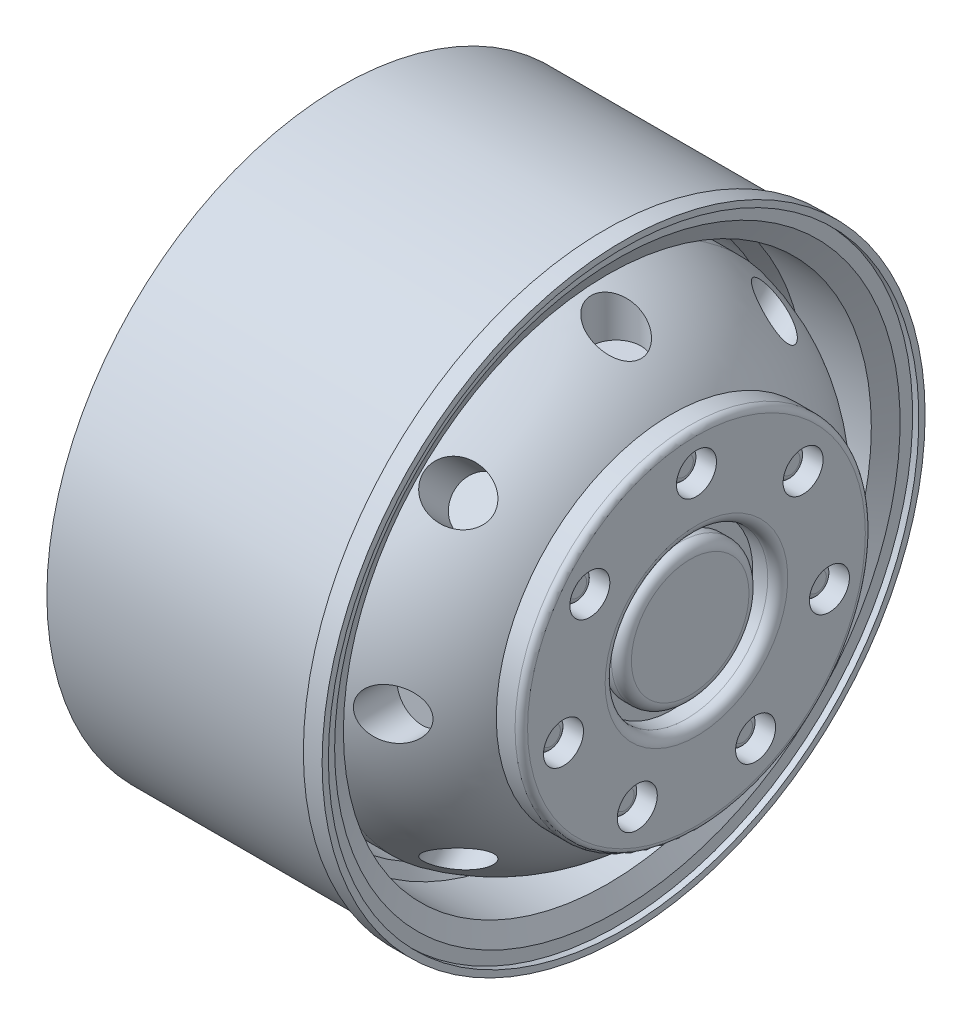
from build123d import *

# Parameters (mm, degrees)
SKETCH2_R           = 6.5
SKETCH2_R_2         = 1.6
CUT_EXTRUDE1_DEPTH  = 2
FILLET1_R           = 0.5
SKETCH3_R           = 1.25
BOSS_EXTRUDE1_DEPTH = 1
FILLET2_R           = 0.5
SKETCH4_R           = 5.5
BOSS_EXTRUDE2_DEPTH = 1.5
FILLET3_R           = 0.8
FILLET4_R           = 0.8
SKETCH6_R           = 2
CUT_EXTRUDE2_DEPTH  = 2.5
CIRPATTERN1_COUNT   = 8


with BuildPart() as part:
    # Sketch1 → Revolve1 (revolve)
    with BuildSketch(Plane.XY):
        with BuildLine():
            Line((-10, 23.5), (11.1, 23.5))
            Line((11.1, 23.5), (11.1, 24.1))
            Line((11.1, 24.1), (12.6, 24.1))
            Line((12.6, 24.1), (12.6, 23.6))
            Line((12.6, 23.6), (12.1, 23.6))
            Line((12.1, 23.6), (12.1, 22.6))
            Line((12.1, 22.6), (11.3, 21.1))
            Line((11.3, 21.1), (6, 21.1))
            Line((6, 21.1), (5.01570057, 20.3))
            Line((5.01570057, 20.3), (0, 20.1))
            Line((0, 20.1), (0, 19.6))
            Line((0, 19.6), (8, 19.6))
            ThreePointArc((8, 19.6), (12.733644996, 17.586085974), (16.421900958, 14))
            Line((16.421900958, 14), (18.421900958, 14))
            Line((18.421900958, 14), (18.421900958, 0))
            Line((18.421900958, 0), (-1.578099042, 0))
            Line((-1.578099042, 0), (-1.460697094, 16.5))
            Line((-1.460697094, 16.5), (-10, 16.5))
            Line((-10, 16.5), (-10, 21.1))
            Line((-10, 21.1), (-10, 23.5))
        make_face()
    revolve(axis=Axis((-25, 0, 0), (1, 0, 0)))

    # Sketch2 → Cut-Extrude1 (cut)
    with BuildSketch(Plane(origin=(18.421900958, 0, 0), x_dir=(0, 0, -1), z_dir=(1, 0, 0))):
        Circle(SKETCH2_R)
        with Locations((0, 10.901204081)):
            Circle(SKETCH2_R_2)
        with Locations((8.522904547, 6.796789572)):
            Circle(SKETCH2_R_2)
        with Locations((10.627888134, -2.425746113)):
            Circle(SKETCH2_R_2)
        with Locations((4.729855187, -9.821645499)):
            Circle(SKETCH2_R_2)
        with Locations((-4.729855187, -9.821645499)):
            Circle(SKETCH2_R_2)
        with Locations((-10.627888134, -2.425746113)):
            Circle(SKETCH2_R_2)
        with Locations((-8.522904547, 6.796789572)):
            Circle(SKETCH2_R_2)
    extrude(amount=-CUT_EXTRUDE1_DEPTH, mode=Mode.SUBTRACT)

    # Fillet1
    fillet1_edges = [part.edges().sort_by_distance(p)[0] for p in [
        (18.421900958, -14, 0),
    ]]
    fillet(fillet1_edges, radius=FILLET1_R)

    # Sketch3 → Boss-Extrude1 (add)
    with BuildSketch(Plane(origin=(16.421900958, 0, 0), x_dir=(0, 0, -1), z_dir=(1, 0, 0))):
        with Locations((0, 10.901204081)):
            Circle(SKETCH3_R)
        with Locations((8.522904547, 6.796789572)):
            Circle(SKETCH3_R)
        with Locations((10.627888134, -2.425746113)):
            Circle(SKETCH3_R)
        with Locations((4.729855187, -9.821645499)):
            Circle(SKETCH3_R)
        with Locations((-4.729855187, -9.821645499)):
            Circle(SKETCH3_R)
        with Locations((-10.627888134, -2.425746113)):
            Circle(SKETCH3_R)
        with Locations((-8.522904547, 6.796789572)):
            Circle(SKETCH3_R)
    extrude(amount=BOSS_EXTRUDE1_DEPTH)

    # Fillet2
    fillet2_edges = [part.edges().sort_by_distance(p)[0] for p in [
        (17.421900958, 10.901204081, 1.25),
        (17.421900958, 6.796789572, -7.272904547),
        (17.421900958, -2.425746113, -9.377888134),
        (17.421900958, -9.821645499, -3.479855187),
        (17.421900958, -9.821645499, 5.979855187),
        (17.421900958, -2.425746113, 11.877888134),
        (17.421900958, 6.796789572, 9.772904547),
    ]]
    fillet(fillet2_edges, radius=FILLET2_R)

    # Sketch4 → Boss-Extrude2 (add)
    with BuildSketch(Plane(origin=(16.421900958, 0, 0), x_dir=(0, 0, -1), z_dir=(1, 0, 0))):
        Circle(SKETCH4_R)
    extrude(amount=BOSS_EXTRUDE2_DEPTH)

    # Fillet3
    fillet3_edges = [part.edges().sort_by_distance(p)[0] for p in [
        (17.921900958, 0, 5.5),
    ]]
    fillet(fillet3_edges, radius=FILLET3_R)

    # Fillet4
    fillet4_edges = [part.edges().sort_by_distance(p)[0] for p in [
        (18.421900958, 0, 6.5),
    ]]
    fillet(fillet4_edges, radius=FILLET4_R)

    # Sketch6 → Cut-Extrude2 (cut, symmetric)
    with BuildSketch(Plane(origin=(0, 18, 0), x_dir=(1, 0, 0), z_dir=(0, 1, 0))):
        with Locations((12, 0)):
            Circle(SKETCH6_R)
    cut_extrude2 = extrude(amount=CUT_EXTRUDE2_DEPTH, both=True, mode=Mode.SUBTRACT)

    # CirPattern1: Cut-Extrude2 ×8 about axis
    cirpattern1_axis = Axis((0, 0, 0), (1, 0, 0))
    for i in range(1, CIRPATTERN1_COUNT):
        add(cut_extrude2.rotate(cirpattern1_axis, i * 360 / CIRPATTERN1_COUNT), mode=Mode.SUBTRACT)


solid = part.part
